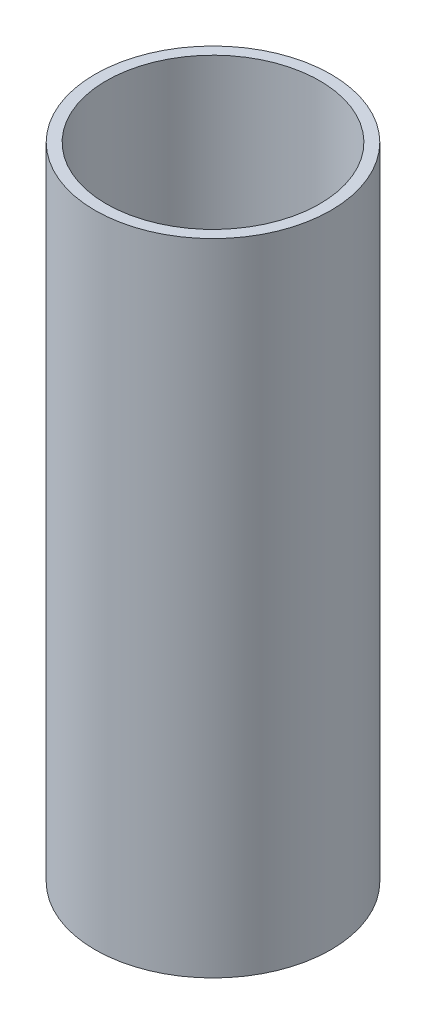
from build123d import *

# Parameters (mm, degrees)
SKETCH1_R           = 21
SKETCH1_R_2         = 19
BOSS_EXTRUDE1_DEPTH = 49
SKETCH1_2_R         = 21
SKETCH1_2_R_2       = 19
BOSS_EXTRUDE2_DEPTH = 114


with BuildPart() as part:
    # Sketch1 → Boss-Extrude1 (new body)
    with BuildSketch(Plane(origin=(0, 0, 0), x_dir=(1, 0, 0), z_dir=(0, 1, 0))):
        Circle(SKETCH1_R)
        Circle(SKETCH1_R_2, mode=Mode.SUBTRACT)
    extrude(amount=BOSS_EXTRUDE1_DEPTH)

    # Sketch1_2 → Boss-Extrude2 (add)
    with BuildSketch(Plane(origin=(0, 0, 0), x_dir=(1, 0, 0), z_dir=(0, 1, 0))):
        Circle(SKETCH1_2_R)
        Circle(SKETCH1_2_R_2, mode=Mode.SUBTRACT)
    extrude(amount=BOSS_EXTRUDE2_DEPTH)


solid = part.part
